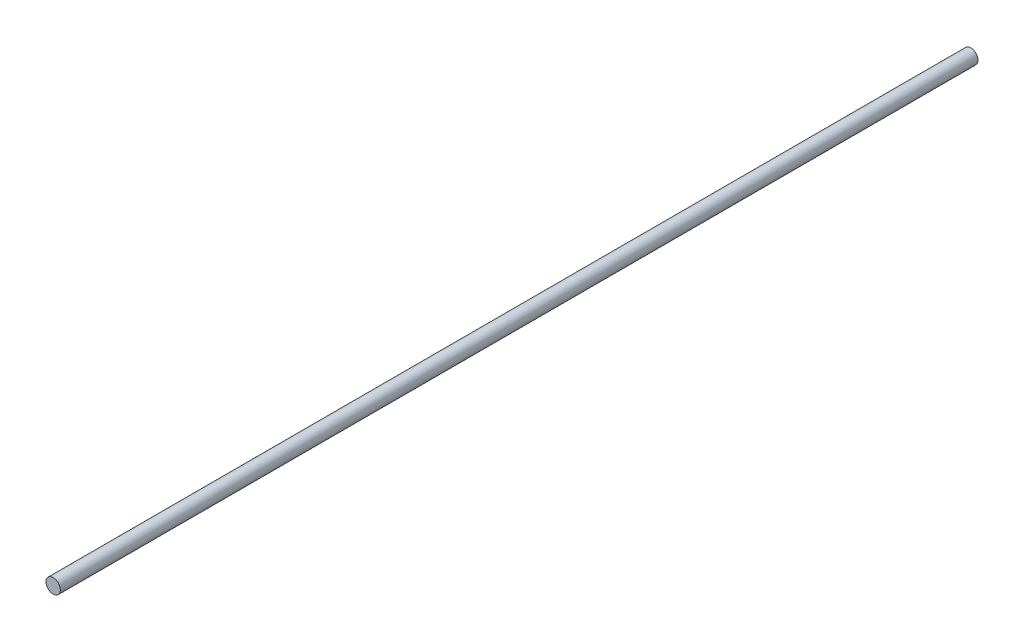
from build123d import *

# Parameters (mm, degrees)
SKETCH1_R           = 6.35
BOSS_EXTRUDE1_DEPTH = 406.4


with BuildPart() as part:
    # Sketch1 → Boss-Extrude1 (new body, symmetric)
    with BuildSketch(Plane.XY):
        Circle(SKETCH1_R)
    extrude(amount=BOSS_EXTRUDE1_DEPTH, both=True)


solid = part.part
